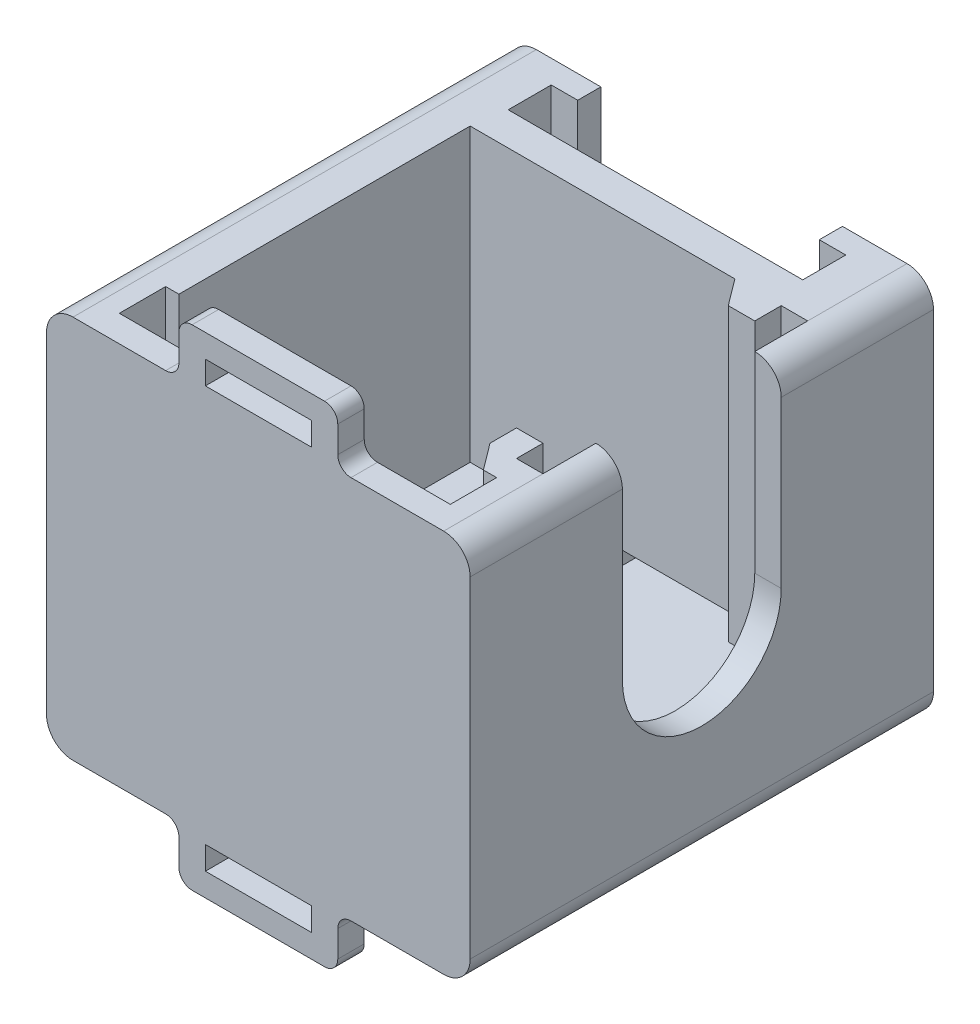
from build123d import *

# Parameters (mm, degrees)
SKETCH1_W                         = 32
SKETCH1_H                         = 29
BOSS_EXTRUDE1_DEPTH               = 35
FILLET1_R                         = 2
SLOT_FOR_COIL_DEPTH               = 1
SLOT_FOR_COIL_DEPTH_BACK          = 30
BOSS_EXTRUDE2_DEPTH               = 7
BOSS_EXTRUDE3_DEPTH               = 1.75
SKETCH5_W                         = 2
SKETCH5_H                         = 7
SLOT_TO_FEED_IN_WIRE_DEPTH        = 33
SLOT_FO_PCB_DEPTH                 = 22
SKETCH7_W                         = 2
SKETCH7_H                         = 33
BOSS_EXTRUDE4_DEPTH               = 0.25
FILLET2_R                         = 6
ROD_MOUNT_SLOT_REACH              = 34
SKETCH14_W                        = 2.5
SKETCH14_H                        = 20
SIDE_CAVITY_FOR_MOUNT_PLATE_DEPTH = 22
SKETCH16_W                        = 2
SKETCH16_H                        = 2
SIDE_STOPS_FOR_MOUNT_PLATE_DEPTH  = 22
BOSS_EXTRUDE6_DEPTH               = 22
SKETCH21_W                        = 12
SKETCH21_H                        = 2
BOSS_EXTRUDE7_DEPTH               = 4
SKETCH23_W                        = 8
SKETCH23_H                        = 1.75
CUT_EXTRUDE7_DEPTH                = 2
FILLET3_R                         = 1
CUT_EXTRUDE8_REACH                = 34
SKETCH26_R                        = 5.5


with BuildPart() as part:
    # Sketch1 → Boss-Extrude1 (new body)
    with BuildSketch(Plane.XY):
        Rectangle(SKETCH1_W, SKETCH1_H)
    extrude(amount=BOSS_EXTRUDE1_DEPTH)

    # Fillet1
    fillet1_edges = [part.edges().sort_by_distance(p)[0] for p in [
        (16, -14.5, 17.5),
        (-16, -14.5, 17.5),
        (-16, 14.5, 17.5),
        (16, 14.5, 17.5),
    ]]
    fillet(fillet1_edges, radius=FILLET1_R)

    # Sketch2 → Slot for Coil (cut, two sides)
    with BuildSketch(Plane.XZ.offset(14.5)) as slot_for_coil_sk:
        Polygon((-9.125, 0), (-9.125, 1.75), (-11.125, 1.75), (-11.125, 5), (11.125, 5), (11.125, 1.75), (9.125, 1.75), (9.125, 0), align=None)
    extrude(amount=SLOT_FOR_COIL_DEPTH, mode=Mode.SUBTRACT)
    extrude(slot_for_coil_sk.sketch, amount=-SLOT_FOR_COIL_DEPTH_BACK, mode=Mode.SUBTRACT)

    # Sketch3 → Boss-Extrude2 (add)
    with BuildSketch(Plane.XZ.offset(14.5)):
        Polygon((-9.125, 0), (-9.125, 1.75), (-11.125, 1.75), (-11.125, 5), (11.125, 5), (11.125, 1.75), (9.125, 1.75), (9.125, 0), align=None)
    extrude(amount=-BOSS_EXTRUDE2_DEPTH)

    # Sketch4 → Boss-Extrude3 (add)
    with BuildSketch(Plane(origin=(0, 0, 1.75), x_dir=(-1, 0, 0), z_dir=(0, 0, -1))):
        with BuildLine():
            Line((-9.125, 7.5), (-9.125, 6.5))
            ThreePointArc((-9.125, 6.5), (-8.875, 7), (-9.125, 7.5))
        make_face()
    boss_extrude3 = extrude(amount=BOSS_EXTRUDE3_DEPTH)

    # Mirror1: Boss-Extrude3 across plane
    add(boss_extrude3.mirror(Plane(origin=(0, 0, 0), x_dir=(0, 0, 1), z_dir=(1, 0, 0))))

    # Sketch5 → slot to feed in wire (cut)
    with BuildSketch(Plane(origin=(0, 0, 0), x_dir=(-1, 0, 0), z_dir=(0, 0, -1))):
        with Locations((0, -11)):
            Rectangle(SKETCH5_W, SKETCH5_H)
    extrude(amount=-SLOT_TO_FEED_IN_WIRE_DEPTH, mode=Mode.SUBTRACT)

    # Sketch6 → slot fo PCB (cut)
    with BuildSketch(Plane(origin=(0, 14.5, 0), x_dir=(1, 0, 0), z_dir=(0, 1, 0))):
        Polygon((11.5, -7.5), (-11.5, -7.5), (-11.5, -29.5), (-12.5, -29.5), (-12.5, -33), (12.5, -33), (12.5, -29.5), (11.5, -29.5), align=None)
    extrude(amount=-SLOT_FO_PCB_DEPTH, mode=Mode.SUBTRACT)

    # Sketch7 → Boss-Extrude4 (add)
    with BuildSketch(Plane.XZ.offset(14.5)):
        with Locations((0, 16.5)):
            Rectangle(SKETCH7_W, SKETCH7_H)
    extrude(amount=-BOSS_EXTRUDE4_DEPTH)

    # Fillet2
    fillet2_edges = [part.edges().sort_by_distance(p)[0] for p in [
        (0, -14.25, 33),
    ]]
    fillet(fillet2_edges, radius=FILLET2_R)

    # Sketch11 → Rod Mount Slot (cut, up to next)
    with BuildSketch(Plane(origin=(16, 0, 44), x_dir=(0, 0, -1), z_dir=(1, 0, 0)), mode=Mode.PRIVATE) as rod_mount_slot_sk1:
        with BuildLine():
            Line((32.5, 25), (32.5, 0))
            ThreePointArc((32.5, 0), (26.5, -6), (20.5, 0))
            Line((20.5, 0), (20.5, 25))
            ThreePointArc((20.5, 25), (26.5, 31), (32.5, 25))
        make_face()
    rod_mount_slot_tool1 = extrude(rod_mount_slot_sk1.sketch, amount=-ROD_MOUNT_SLOT_REACH, mode=Mode.PRIVATE) & part.part
    add(rod_mount_slot_tool1.solids().sort_by_distance((16, 12.5, 17.5))[0], mode=Mode.SUBTRACT)

    # Sketch14 → Side cavity for mount plate (cut)
    with BuildSketch(Plane(origin=(0, 14.5, 0), x_dir=(1, 0, 0), z_dir=(0, 1, 0))):
        with Locations((12.75, -17.5)):
            Rectangle(SKETCH14_W, SKETCH14_H)
    extrude(amount=-SIDE_CAVITY_FOR_MOUNT_PLATE_DEPTH, mode=Mode.SUBTRACT)

    # Sketch16 → Side stops for mount plate (add)
    with BuildSketch(Plane(origin=(0, 14.5, 0), x_dir=(1, 0, 0), z_dir=(0, 1, 0))):
        with Locations((11, -8.5)):
            Rectangle(SKETCH16_W, SKETCH16_H)
        with Locations((11, -26.5)):
            Rectangle(SKETCH16_W, SKETCH16_H)
    extrude(amount=-SIDE_STOPS_FOR_MOUNT_PLATE_DEPTH)

    # Sketch20 → Boss-Extrude6 (add)
    with BuildSketch(Plane(origin=(0, 14.5, 0), x_dir=(1, 0, 0), z_dir=(0, 1, 0))):
        Polygon((11.5, -29.5), (10, -27.5), (11.5, -27.5), align=None)
        Polygon((10, -9.5), (8.5, -7.5), (10, -7.5), align=None)
    extrude(amount=-BOSS_EXTRUDE6_DEPTH)

    # Sketch21 → Boss-Extrude7 (add)
    with BuildSketch(Plane(origin=(0, 14.5, 0), x_dir=(-1, 0, 0), z_dir=(0, 1, 0))):
        with Locations((0, 34)):
            Rectangle(SKETCH21_W, SKETCH21_H)
    boss_extrude7 = extrude(amount=BOSS_EXTRUDE7_DEPTH)

    # Sketch23 → Cut-Extrude7 (cut)
    with BuildSketch(Plane.XY.offset(35)):
        with Locations((0, 15.875)):
            Rectangle(SKETCH23_W, SKETCH23_H)
    cut_extrude7 = extrude(amount=-CUT_EXTRUDE7_DEPTH, mode=Mode.SUBTRACT)

    # Mirror3: Boss-Extrude7, Cut-Extrude7 across plane
    add(boss_extrude7.mirror(Plane.ZX))
    add(cut_extrude7.mirror(Plane.ZX), mode=Mode.SUBTRACT)

    # Fillet3
    fillet3_edges = [part.edges().sort_by_distance(p)[0] for p in [
        (6, 14.5, 34),
        (-6, 14.5, 34),
        (6, 18.5, 34),
        (-6, 18.5, 34),
        (6, -18.5, 34),
        (-6, -18.5, 34),
        (6, -14.5, 34),
        (-6, -14.5, 34),
    ]]
    fillet(fillet3_edges, radius=FILLET3_R)

    # Sketch26 → Cut-Extrude8 (cut, up to next)
    with BuildSketch(Plane(origin=(-16, 0, 0), x_dir=(0, 0, -1), z_dir=(1, 0, 0)), mode=Mode.PRIVATE) as cut_extrude8_sk1:
        with Locations((-23.015, -2.89)):
            Circle(SKETCH26_R)
    cut_extrude8_tool1 = extrude(cut_extrude8_sk1.sketch, amount=CUT_EXTRUDE8_REACH, mode=Mode.PRIVATE) & part.part
    add(cut_extrude8_tool1.solids().sort_by_distance((-16, -2.89, 23.015))[0], mode=Mode.SUBTRACT)


solid = part.part
